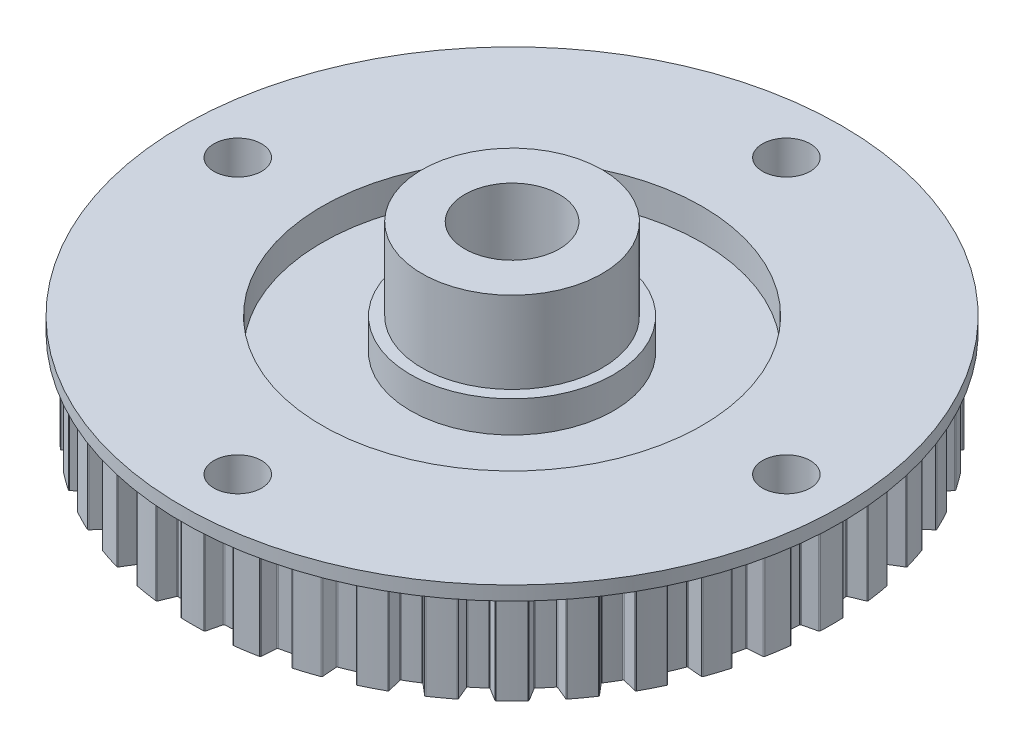
from build123d import *

# Parameters (mm, degrees)
CUT_EXTRUDE4_REACH       = 12.8
SKETCH2_R                = 2.4
BOSS_EXTRUDE1_DEPTH      = 9.4
FILLET1_R                = 0.1
CIRPATTERN1_COUNT        = 40
FILLET1_OF_CIRPATTERN1_R = 0.1


with BuildPart() as part:
    # Sketch1 → Revolve1 (revolve)
    with BuildSketch(Plane.XY):
        Polygon((4.75, 0), (4.75, 19), (9.05, 19), (9.05, 10.8), (10.2, 10.8), (10.2, 7.65), (19.075, 7.65), (19.075, 10.8), (33.1, 10.8), (33.1, 9.4), (30.55, 9.4), (30.55, 0), (25.125, 0), (25.125, 3.6), (12.65, 3.6), (12.65, 0), align=None)
    revolve(axis=Axis((0, 0, 0), (0, 1, 0)))

    # Sketch2 → Cut-Extrude4 (cut, up to next)
    with BuildSketch(Plane(origin=(0, 10.8, 0), x_dir=(1, 0, 0), z_dir=(0, 1, 0)), mode=Mode.PRIVATE) as cut_extrude4_sk1:
        with Locations((-27.55, 0)):
            Circle(SKETCH2_R)
    cut_extrude4_tool1 = extrude(cut_extrude4_sk1.sketch, amount=-CUT_EXTRUDE4_REACH, mode=Mode.PRIVATE) & part.part
    add(cut_extrude4_tool1.solids().sort_by_distance((-27.55, 10.8, 0))[0], mode=Mode.SUBTRACT)
    # Sketch2 → Cut-Extrude4 (cut, up to next)
    with BuildSketch(Plane(origin=(0, 10.8, 0), x_dir=(1, 0, 0), z_dir=(0, 1, 0)), mode=Mode.PRIVATE) as cut_extrude4_sk2:
        with Locations((0, 27.55)):
            Circle(SKETCH2_R)
    cut_extrude4_tool2 = extrude(cut_extrude4_sk2.sketch, amount=-CUT_EXTRUDE4_REACH, mode=Mode.PRIVATE) & part.part
    add(cut_extrude4_tool2.solids().sort_by_distance((0, 10.8, -27.55))[0], mode=Mode.SUBTRACT)
    # Sketch2 → Cut-Extrude4 (cut, up to next)
    with BuildSketch(Plane(origin=(0, 10.8, 0), x_dir=(1, 0, 0), z_dir=(0, 1, 0)), mode=Mode.PRIVATE) as cut_extrude4_sk3:
        with Locations((27.55, 0)):
            Circle(SKETCH2_R)
    cut_extrude4_tool3 = extrude(cut_extrude4_sk3.sketch, amount=-CUT_EXTRUDE4_REACH, mode=Mode.PRIVATE) & part.part
    add(cut_extrude4_tool3.solids().sort_by_distance((27.55, 10.8, 0))[0], mode=Mode.SUBTRACT)
    # Sketch2 → Cut-Extrude4 (cut, up to next)
    with BuildSketch(Plane(origin=(0, 10.8, 0), x_dir=(1, 0, 0), z_dir=(0, 1, 0)), mode=Mode.PRIVATE) as cut_extrude4_sk4:
        with Locations((0, -27.55)):
            Circle(SKETCH2_R)
    cut_extrude4_tool4 = extrude(cut_extrude4_sk4.sketch, amount=-CUT_EXTRUDE4_REACH, mode=Mode.PRIVATE) & part.part
    add(cut_extrude4_tool4.solids().sort_by_distance((0, 10.8, 27.55))[0], mode=Mode.SUBTRACT)

    # Sketch3 → Boss-Extrude1 (add)
    with BuildSketch(Plane.XZ):
        with BuildLine():
            Line((1.575, 30.50937356), (1.2, 32.077562252))
            ThreePointArc((1.2, 32.077562252), (0, 32.1), (-1.2, 32.077562252))
            Line((-1.2, 32.077562252), (-1.575, 30.50937356))
            ThreePointArc((-1.575, 30.50937356), (0, 30.55), (1.575, 30.50937356))
        make_face()
    boss_extrude1 = extrude(amount=-BOSS_EXTRUDE1_DEPTH)

    # Fillet1
    fillet1_edges = [part.edges().sort_by_distance(p)[0] for p in [
        (-1.575, 4.7, 30.50937356),
        (-1.2, 4.7, 32.077562252),
        (1.2, 4.7, 32.077562252),
        (1.575, 4.7, 30.50937356),
    ]]
    fillet(fillet1_edges, radius=FILLET1_R)

    # CirPattern1: Boss-Extrude1 ×40 about axis
    cirpattern1_axis = Axis((0, 0, 0), (0, 1, 0))
    for i in range(1, CIRPATTERN1_COUNT):
        add(boss_extrude1.rotate(cirpattern1_axis, i * 360 / CIRPATTERN1_COUNT))

    # Fillet1 of CirPattern1
    fillet1_of_cirpattern1_edges = [part.edges().sort_by_distance(p)[0] for p in [
        (3.217108395, 4.7, 30.380136826),
        (3.832810282, 4.7, 31.870355589),
        (6.203262299, 4.7, 31.494912872),
        (6.328326668, 4.7, 29.887368261),
        (7.930000904, 4.7, 29.502840298),
        (8.771244054, 4.7, 30.878394999),
        (11.053779693, 4.7, 30.136754213),
        (10.925828931, 4.7, 28.529436766),
        (12.447630473, 4.7, 27.899085928),
        (13.493700688, 4.7, 29.126105846),
        (15.632116346, 4.7, 28.036528646),
        (15.254301025, 4.7, 26.469015853),
        (16.658758069, 4.7, 25.60836347),
        (17.883897628, 4.7, 26.656635302),
        (19.825538414, 4.7, 25.245950697),
        (19.207161601, 4.7, 23.756839925),
        (20.459691753, 4.7, 22.687078114),
        (21.833733655, 4.7, 23.530789929),
        (23.530789929, 4.7, 21.833733655),
        (22.687078114, 4.7, 20.459691753),
        (23.756839925, 4.7, 19.207161601),
        (25.245950697, 4.7, 19.825538414),
        (26.656635302, 4.7, 17.883897628),
        (25.60836347, 4.7, 16.658758069),
        (26.469015853, 4.7, 15.254301025),
        (28.036528646, 4.7, 15.632116346),
        (29.126105846, 4.7, 13.493700688),
        (27.899085928, 4.7, 12.447630473),
        (28.529436766, 4.7, 10.925828931),
        (30.136754213, 4.7, 11.053779693),
        (30.878394999, 4.7, 8.771244054),
        (29.502840298, 4.7, 7.930000904),
        (29.887368261, 4.7, 6.328326668),
        (31.494912872, 4.7, 6.203262299),
        (31.870355589, 4.7, 3.832810282),
        (30.380136826, 4.7, 3.217108395),
        (30.50937356, 4.7, 1.575),
        (32.077562252, 4.7, 1.2),
        (32.077562252, 4.7, -1.2),
        (30.50937356, 4.7, -1.575),
        (30.380136826, 4.7, -3.217108395),
        (31.870355589, 4.7, -3.832810282),
        (31.494912872, 4.7, -6.203262299),
        (29.887368261, 4.7, -6.328326668),
        (29.502840298, 4.7, -7.930000904),
        (30.878394999, 4.7, -8.771244054),
        (30.136754213, 4.7, -11.053779693),
        (28.529436766, 4.7, -10.925828931),
        (27.899085928, 4.7, -12.447630473),
        (29.126105846, 4.7, -13.493700688),
        (28.036528646, 4.7, -15.632116346),
        (26.469015853, 4.7, -15.254301025),
        (25.60836347, 4.7, -16.658758069),
        (26.656635302, 4.7, -17.883897628),
        (25.245950697, 4.7, -19.825538414),
        (23.756839925, 4.7, -19.207161601),
        (22.687078114, 4.7, -20.459691753),
        (23.530789929, 4.7, -21.833733655),
        (21.833733655, 4.7, -23.530789929),
        (20.459691753, 4.7, -22.687078114),
        (19.207161601, 4.7, -23.756839925),
        (19.825538414, 4.7, -25.245950697),
        (17.883897628, 4.7, -26.656635302),
        (16.658758069, 4.7, -25.60836347),
        (15.254301025, 4.7, -26.469015853),
        (15.632116346, 4.7, -28.036528646),
        (13.493700688, 4.7, -29.126105846),
        (12.447630473, 4.7, -27.899085928),
        (10.925828931, 4.7, -28.529436766),
        (11.053779693, 4.7, -30.136754213),
        (8.771244054, 4.7, -30.878394999),
        (7.930000904, 4.7, -29.502840298),
        (6.328326668, 4.7, -29.887368261),
        (6.203262299, 4.7, -31.494912872),
        (3.832810282, 4.7, -31.870355589),
        (3.217108395, 4.7, -30.380136826),
        (1.575, 4.7, -30.50937356),
        (1.2, 4.7, -32.077562252),
        (-1.2, 4.7, -32.077562252),
        (-1.575, 4.7, -30.50937356),
        (-3.217108395, 4.7, -30.380136826),
        (-3.832810282, 4.7, -31.870355589),
        (-6.203262299, 4.7, -31.494912872),
        (-6.328326668, 4.7, -29.887368261),
        (-7.930000904, 4.7, -29.502840298),
        (-8.771244054, 4.7, -30.878394999),
        (-11.053779693, 4.7, -30.136754213),
        (-10.925828931, 4.7, -28.529436766),
        (-12.447630473, 4.7, -27.899085928),
        (-13.493700688, 4.7, -29.126105846),
        (-15.632116346, 4.7, -28.036528646),
        (-15.254301025, 4.7, -26.469015853),
        (-16.658758069, 4.7, -25.60836347),
        (-17.883897628, 4.7, -26.656635302),
        (-19.825538414, 4.7, -25.245950697),
        (-19.207161601, 4.7, -23.756839925),
        (-20.459691753, 4.7, -22.687078114),
        (-21.833733655, 4.7, -23.530789929),
        (-23.530789929, 4.7, -21.833733655),
        (-22.687078114, 4.7, -20.459691753),
        (-23.756839925, 4.7, -19.207161601),
        (-25.245950697, 4.7, -19.825538414),
        (-26.656635302, 4.7, -17.883897628),
        (-25.60836347, 4.7, -16.658758069),
        (-26.469015853, 4.7, -15.254301025),
        (-28.036528646, 4.7, -15.632116346),
        (-29.126105846, 4.7, -13.493700688),
        (-27.899085928, 4.7, -12.447630473),
        (-28.529436766, 4.7, -10.925828931),
        (-30.136754213, 4.7, -11.053779693),
        (-30.878394999, 4.7, -8.771244054),
        (-29.502840298, 4.7, -7.930000904),
        (-29.887368261, 4.7, -6.328326668),
        (-31.494912872, 4.7, -6.203262299),
        (-31.870355589, 4.7, -3.832810282),
        (-30.380136826, 4.7, -3.217108395),
        (-30.50937356, 4.7, -1.575),
        (-32.077562252, 4.7, -1.2),
        (-32.077562252, 4.7, 1.2),
        (-30.50937356, 4.7, 1.575),
        (-30.380136826, 4.7, 3.217108395),
        (-31.870355589, 4.7, 3.832810282),
        (-31.494912872, 4.7, 6.203262299),
        (-29.887368261, 4.7, 6.328326668),
        (-29.502840298, 4.7, 7.930000904),
        (-30.878394999, 4.7, 8.771244054),
        (-30.136754213, 4.7, 11.053779693),
        (-28.529436766, 4.7, 10.925828931),
        (-27.899085928, 4.7, 12.447630473),
        (-29.126105846, 4.7, 13.493700688),
        (-28.036528646, 4.7, 15.632116346),
        (-26.469015853, 4.7, 15.254301025),
        (-25.60836347, 4.7, 16.658758069),
        (-26.656635302, 4.7, 17.883897628),
        (-25.245950697, 4.7, 19.825538414),
        (-23.756839925, 4.7, 19.207161601),
        (-22.687078114, 4.7, 20.459691753),
        (-23.530789929, 4.7, 21.833733655),
        (-21.833733655, 4.7, 23.530789929),
        (-20.459691753, 4.7, 22.687078114),
        (-19.207161601, 4.7, 23.756839925),
        (-19.825538414, 4.7, 25.245950697),
        (-17.883897628, 4.7, 26.656635302),
        (-16.658758069, 4.7, 25.60836347),
        (-15.254301025, 4.7, 26.469015853),
        (-15.632116346, 4.7, 28.036528646),
        (-13.493700688, 4.7, 29.126105846),
        (-12.447630473, 4.7, 27.899085928),
        (-10.925828931, 4.7, 28.529436766),
        (-11.053779693, 4.7, 30.136754213),
        (-8.771244054, 4.7, 30.878394999),
        (-7.930000904, 4.7, 29.502840298),
        (-6.328326668, 4.7, 29.887368261),
        (-6.203262299, 4.7, 31.494912872),
        (-3.832810282, 4.7, 31.870355589),
        (-3.217108395, 4.7, 30.380136826),
    ]]
    fillet(fillet1_of_cirpattern1_edges, radius=FILLET1_OF_CIRPATTERN1_R)


solid = part.part
